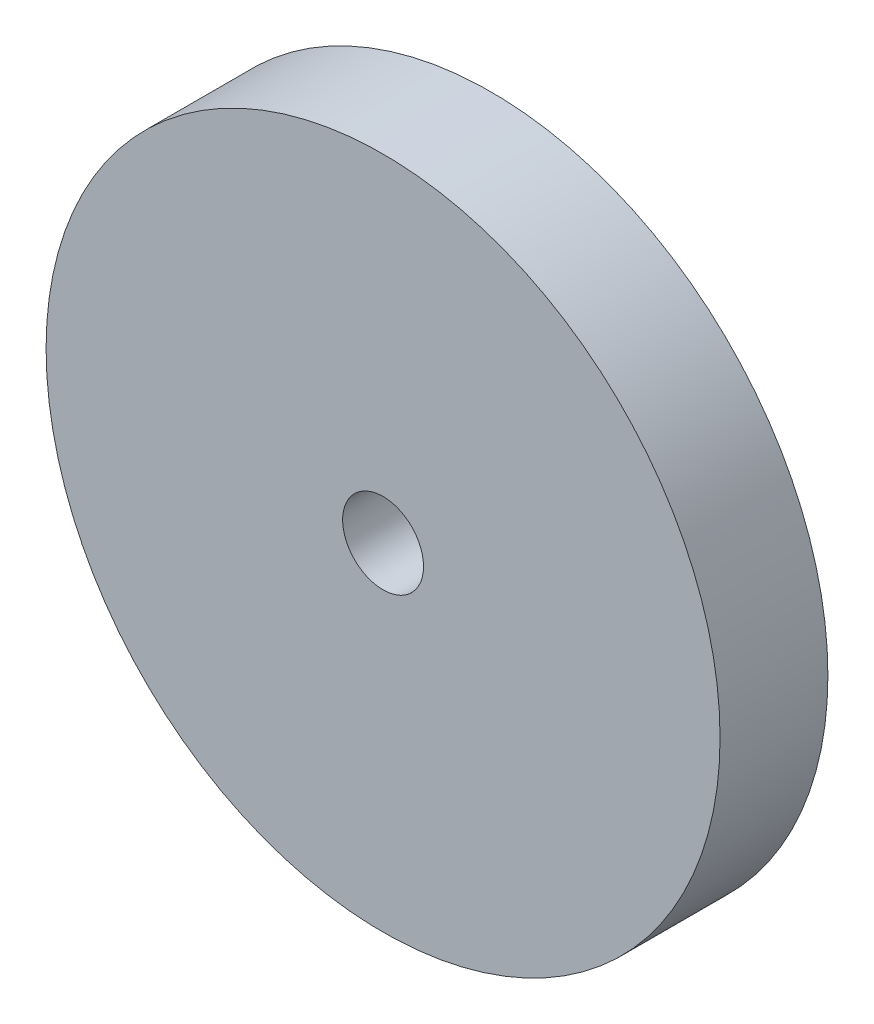
from build123d import *

# Parameters (mm, degrees)
SKETCH_1_R      = 12.5
SKETCH_1_R_2    = 1.5
EXTRUDE_1_DEPTH = 4


with BuildPart() as part:
    # Эскиз1 → Бобышка-Вытянуть1 (new body)
    with BuildSketch(Plane.XY):
        Circle(SKETCH_1_R)
        Circle(SKETCH_1_R_2, mode=Mode.SUBTRACT)
    extrude(amount=EXTRUDE_1_DEPTH)


solid = part.part
